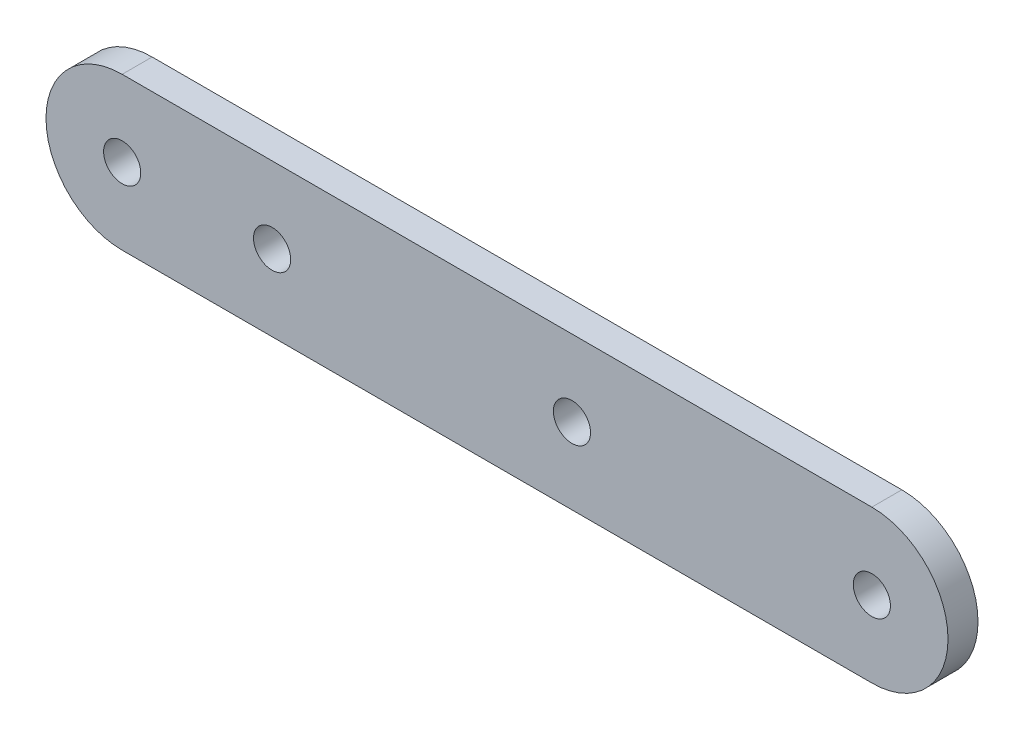
from build123d import *

# Parameters (mm, degrees)
SKETCH1_R           = 3.1
BOSS_EXTRUDE1_DEPTH = 5


with BuildPart() as part:
    # Sketch1 → Boss-Extrude1 (new body)
    with BuildSketch(Plane.XY):
        with BuildLine():
            Line((0, -12.7), (125, -12.7))
            ThreePointArc((125, -12.7), (137.7, 0), (125, 12.7))
            Line((125, 12.7), (0, 12.7))
            ThreePointArc((0, 12.7), (-12.7, 0), (0, -12.7))
        make_face()
        Circle(SKETCH1_R, mode=Mode.SUBTRACT)
        with Locations((125, 0)):
            Circle(SKETCH1_R, mode=Mode.SUBTRACT)
        with Locations((25, 0)):
            Circle(SKETCH1_R, mode=Mode.SUBTRACT)
        with Locations((75, 0)):
            Circle(SKETCH1_R, mode=Mode.SUBTRACT)
    extrude(amount=BOSS_EXTRUDE1_DEPTH)


solid = part.part
